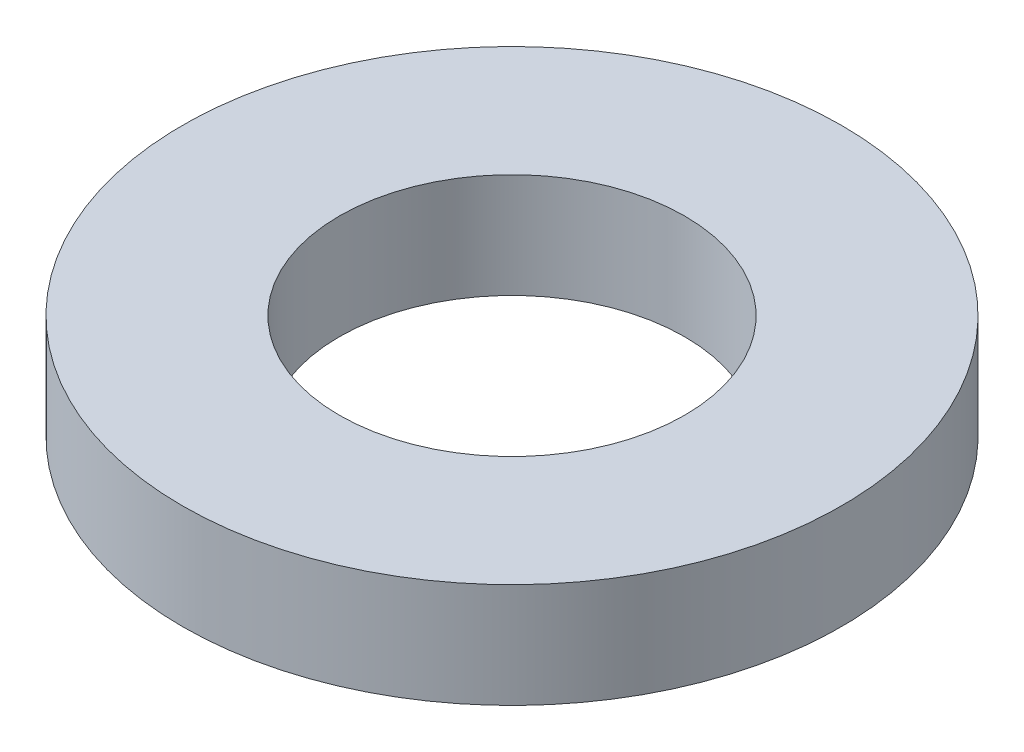
from build123d import *

# Parameters (mm, degrees)
SKETCH1_R           = 31.5
SKETCH1_R_2         = 16.5
BOSS_EXTRUDE1_DEPTH = 10


with BuildPart() as part:
    # Sketch1 → Boss-Extrude1 (new body)
    with BuildSketch(Plane(origin=(0, 0, 0), x_dir=(1, 0, 0), z_dir=(0, 1, 0))):
        Circle(SKETCH1_R)
        Circle(SKETCH1_R_2, mode=Mode.SUBTRACT)
    extrude(amount=BOSS_EXTRUDE1_DEPTH)


solid = part.part
